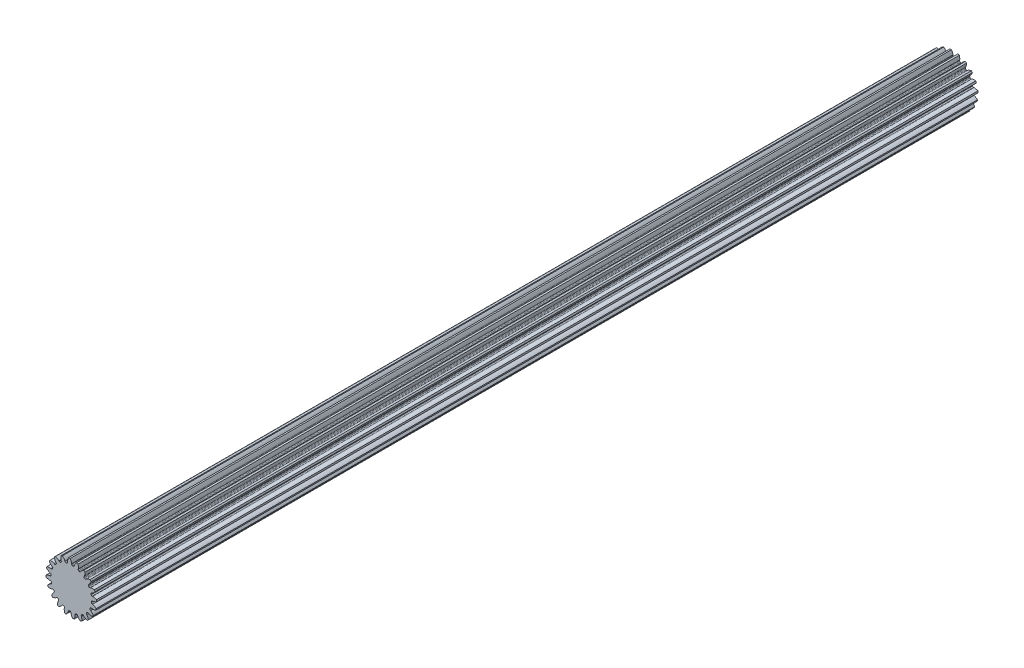
from build123d import *

# Parameters (mm, degrees)
SKETCH1_R                = 8.763
BOSS_EXTRUDE1_DEPTH      = 304.8
CUT_EXTRUDE1_DEPTH       = 305.8
FILLET1_R                = 0.311705625
CIRPATTERN1_COUNT        = 20
FILLET1_OF_CIRPATTERN1_R = 0.311705625


with BuildPart() as part:
    # Sketch1 → Boss-Extrude1 (new body)
    with BuildSketch(Plane.XY):
        Circle(SKETCH1_R)
    extrude(amount=-BOSS_EXTRUDE1_DEPTH)

    # Sketch4 → Cut-Extrude1 (cut, through all)
    with BuildSketch(Plane.XY):
        with BuildLine():
            Line((0.129659117, 7.457683137), (0.129659117, 7.0179336))
            ThreePointArc((0.129659117, 7.0179336), (0.550715976, 6.99749351), (0.969786444, 6.95181399))
            Line((0.969786444, 6.95181399), (1.038578587, 7.386149456))
            add(Edge.make_bspline(
                [(2.617270175, 9.278720795), (1.469881899, 8.555671015), (1.038578587, 7.386149456)],
                knots=[0, 0, 0, 1, 1, 1], degree=2))
            ThreePointArc((2.617270175, 9.278720795), (0.75640915, 9.611066952), (-1.133531995, 9.573916021))
            add(Edge.make_bspline(
                [(-1.133531995, 9.573916021), (-0.113380207, 8.680276738), (0.129659117, 7.457683137)],
                knots=[0, 0, 0, 1, 1, 1], degree=2))
        make_face()
    cut_extrude1 = extrude(amount=-CUT_EXTRUDE1_DEPTH, mode=Mode.SUBTRACT)

    # Fillet1
    fillet1_edges = [part.edges().sort_by_distance(p)[0] for p in [
        (0.969786444, 6.95181399, -152.4),
        (0.129659117, 7.0179336, -152.4),
    ]]
    fillet(fillet1_edges, radius=FILLET1_R)

    # CirPattern1: Cut-Extrude1 ×20 about axis
    cirpattern1_axis = Axis((0, 0, -304.8), (0, 0, 1))
    for i in range(1, CIRPATTERN1_COUNT):
        add(cut_extrude1.rotate(cirpattern1_axis, i * 360 / CIRPATTERN1_COUNT), mode=Mode.SUBTRACT)

    # Fillet1 of CirPattern1
    fillet1_of_cirpattern1_edges = [part.edges().sort_by_distance(p)[0] for p in [
        (-1.225906948, 6.911248488, -152.4),
        (-2.0453476, 6.714518352, -152.4),
        (-3.301600026, 6.19416183, -152.4),
        (-4.020141443, 5.753839265, -152.4),
        (-5.05410949, 4.870747454, -152.4),
        (-5.601415831, 4.229934301, -152.4),
        (-6.311887504, 3.070550382, -152.4),
        (-6.634384611, 2.291973896, -152.4),
        (-6.95181399, 0.969786444, -152.4),
        (-7.0179336, 0.129659117, -152.4),
        (-6.911248488, -1.225906948, -152.4),
        (-6.714518352, -2.0453476, -152.4),
        (-6.19416183, -3.301600026, -152.4),
        (-5.753839265, -4.020141443, -152.4),
        (-4.870747454, -5.05410949, -152.4),
        (-4.229934301, -5.601415831, -152.4),
        (-3.070550382, -6.311887504, -152.4),
        (-2.291973896, -6.634384611, -152.4),
        (-0.969786444, -6.95181399, -152.4),
        (-0.129659117, -7.0179336, -152.4),
        (1.225906948, -6.911248488, -152.4),
        (2.0453476, -6.714518352, -152.4),
        (3.301600026, -6.19416183, -152.4),
        (4.020141443, -5.753839265, -152.4),
        (5.05410949, -4.870747454, -152.4),
        (5.601415831, -4.229934301, -152.4),
        (6.311887504, -3.070550382, -152.4),
        (6.634384611, -2.291973896, -152.4),
        (6.95181399, -0.969786444, -152.4),
        (7.0179336, -0.129659117, -152.4),
        (6.911248488, 1.225906948, -152.4),
        (6.714518352, 2.0453476, -152.4),
        (6.19416183, 3.301600026, -152.4),
        (5.753839265, 4.020141443, -152.4),
        (4.870747454, 5.05410949, -152.4),
        (4.229934301, 5.601415831, -152.4),
        (3.070550382, 6.311887504, -152.4),
        (2.291973896, 6.634384611, -152.4),
    ]]
    fillet(fillet1_of_cirpattern1_edges, radius=FILLET1_OF_CIRPATTERN1_R)


solid = part.part
